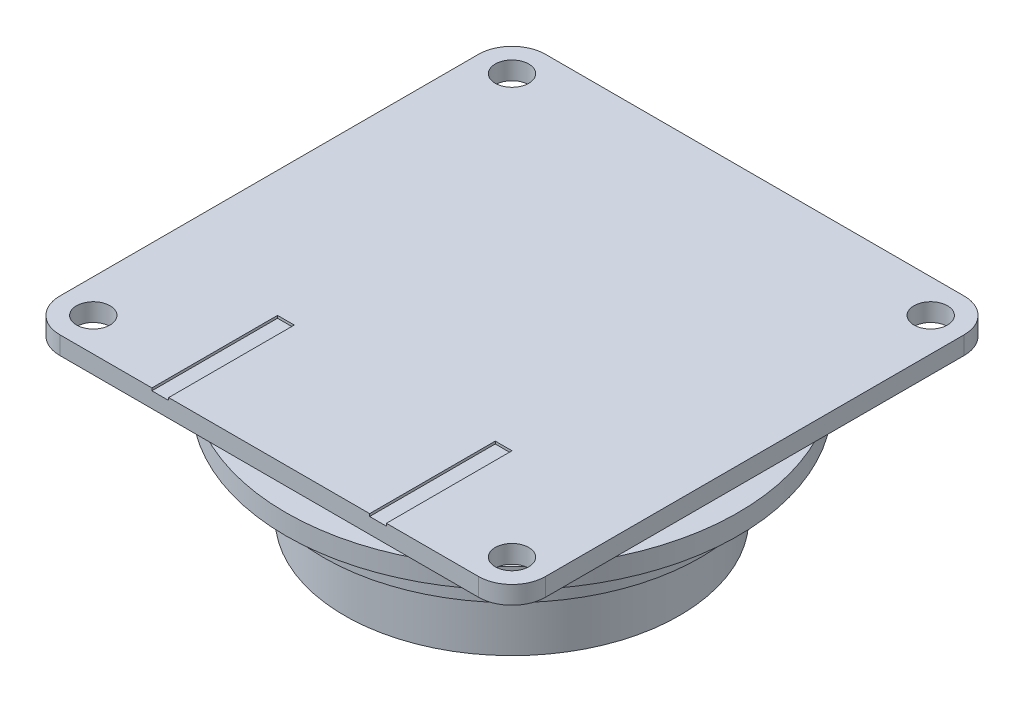
from build123d import *

# Parameters (mm, degrees)
SKETCH1_R            = 20
BOSS_EXTRUDE1_DEPTH  = 7.25
SKETCH2_R            = 22.5
BOSS_EXTRUDE2_DEPTH  = 4.5
SKETCH3_R            = 27
BOSS_EXTRUDE3_DEPTH  = 2.4
CUT_EXTRUDE1_REACH   = 42.721
SKETCH4_R            = 1
SKETCH5_R            = 23.5
BOSS_EXTRUDE4_DEPTH  = 2.5
SKETCH6_R            = 20.5
BOSS_EXTRUDE5_DEPTH  = 1
SKETCH8_R            = 17.25
BOSS_EXTRUDE8_DEPTH  = 1.25
SKETCH10_R           = 2
BOSS_EXTRUDE10_DEPTH = 2.15
SKETCH11_W           = 2
SKETCH11_H           = 15
CUT_EXTRUDE2_DEPTH   = 0.3


with BuildPart() as part:
    # Sketch1 → Boss-Extrude1 (new body)
    with BuildSketch(Plane(origin=(0, 0, 0), x_dir=(1, 0, 0), z_dir=(0, 1, 0))):
        with Locations(Location((0, 0, 0), (0, 0, 90))):
            Circle(SKETCH1_R)
    extrude(amount=BOSS_EXTRUDE1_DEPTH)

    # Sketch2 → Boss-Extrude2 (add)
    with BuildSketch(Plane(origin=(0, 7.25, 0), x_dir=(1, 0, 0), z_dir=(0, 1, 0))):
        with Locations(Location((0, 0, 0), (0, 0, 270))):
            Circle(SKETCH2_R)
    extrude(amount=BOSS_EXTRUDE2_DEPTH)

    # Sketch3 → Boss-Extrude3 (add)
    with BuildSketch(Plane(origin=(0, 11.75, 0), x_dir=(1, 0, 0), z_dir=(0, 1, 0))):
        with Locations(Location((0, 0, 0), (0, 0, 270))):
            Circle(SKETCH3_R)
    extrude(amount=BOSS_EXTRUDE3_DEPTH)

    # Sketch4 → Cut-Extrude1 (cut, up to next)
    with BuildSketch(Plane(origin=(0, 14.15, 0), x_dir=(1, 0, 0), z_dir=(0, 1, 0)), mode=Mode.PRIVATE) as cut_extrude1_sk1:
        with Locations(Location((17.735675135, -15.417387181, 0), (0, 0, 270))):
            Circle(SKETCH4_R)
    cut_extrude1_tool1 = extrude(cut_extrude1_sk1.sketch, amount=-CUT_EXTRUDE1_REACH, mode=Mode.PRIVATE) & part.part
    # Sketch4 → Cut-Extrude1 (cut, up to next)
    with BuildSketch(Plane(origin=(0, 14.15, 0), x_dir=(1, 0, 0), z_dir=(0, 1, 0)), mode=Mode.PRIVATE) as cut_extrude1_sk2:
        with Locations(Location((-4.484011391, -23.068238811, 0), (0, 0, 270))):
            Circle(SKETCH4_R)
    cut_extrude1_tool2 = extrude(cut_extrude1_sk2.sketch, amount=-CUT_EXTRUDE1_REACH, mode=Mode.PRIVATE) & part.part
    # Sketch4 → Cut-Extrude1 (cut, up to next)
    with BuildSketch(Plane(origin=(0, 14.15, 0), x_dir=(1, 0, 0), z_dir=(0, 1, 0)), mode=Mode.PRIVATE) as cut_extrude1_sk3:
        with Locations(Location((-22.219686527, -7.65085163, 0), (0, 0, 270))):
            Circle(SKETCH4_R)
    cut_extrude1_tool3 = extrude(cut_extrude1_sk3.sketch, amount=-CUT_EXTRUDE1_REACH, mode=Mode.PRIVATE) & part.part
    # Sketch4 → Cut-Extrude1 (cut, up to next)
    with BuildSketch(Plane(origin=(0, 14.15, 0), x_dir=(1, 0, 0), z_dir=(0, 1, 0)), mode=Mode.PRIVATE) as cut_extrude1_sk4:
        with Locations(Location((-17.735675135, 15.417387181, 0), (0, 0, 270))):
            Circle(SKETCH4_R)
    cut_extrude1_tool4 = extrude(cut_extrude1_sk4.sketch, amount=-CUT_EXTRUDE1_REACH, mode=Mode.PRIVATE) & part.part
    # Sketch4 → Cut-Extrude1 (cut, up to next)
    with BuildSketch(Plane(origin=(0, 14.15, 0), x_dir=(1, 0, 0), z_dir=(0, 1, 0)), mode=Mode.PRIVATE) as cut_extrude1_sk5:
        with Locations(Location((4.484011391, 23.068238811, 0), (0, 0, 270))):
            Circle(SKETCH4_R)
    cut_extrude1_tool5 = extrude(cut_extrude1_sk5.sketch, amount=-CUT_EXTRUDE1_REACH, mode=Mode.PRIVATE) & part.part
    # Sketch4 → Cut-Extrude1 (cut, up to next)
    with BuildSketch(Plane(origin=(0, 14.15, 0), x_dir=(1, 0, 0), z_dir=(0, 1, 0)), mode=Mode.PRIVATE) as cut_extrude1_sk6:
        with Locations(Location((22.219686527, 7.65085163, 0), (0, 0, 270))):
            Circle(SKETCH4_R)
    cut_extrude1_tool6 = extrude(cut_extrude1_sk6.sketch, amount=-CUT_EXTRUDE1_REACH, mode=Mode.PRIVATE) & part.part
    add(cut_extrude1_tool1.solids().sort_by_distance((17.735675, 14.15, 15.417387))[0], mode=Mode.SUBTRACT)
    add(cut_extrude1_tool2.solids().sort_by_distance((-4.484011, 14.15, 23.068239))[0], mode=Mode.SUBTRACT)
    add(cut_extrude1_tool3.solids().sort_by_distance((-22.219687, 14.15, 7.650852))[0], mode=Mode.SUBTRACT)
    add(cut_extrude1_tool4.solids().sort_by_distance((-17.735675, 14.15, -15.417387))[0], mode=Mode.SUBTRACT)
    add(cut_extrude1_tool5.solids().sort_by_distance((4.484011, 14.15, -23.068239))[0], mode=Mode.SUBTRACT)
    add(cut_extrude1_tool6.solids().sort_by_distance((22.219687, 14.15, -7.650852))[0], mode=Mode.SUBTRACT)

    # Sketch5 → Boss-Extrude4 (add)
    with BuildSketch(Plane(origin=(0, 14.15, 0), x_dir=(1, 0, 0), z_dir=(0, 1, 0))):
        with Locations(Location((0, 0, 0), (0, 0, 81.438302268))):
            Circle(SKETCH5_R)
    extrude(amount=BOSS_EXTRUDE4_DEPTH)

    # Sketch6 → Boss-Extrude5 (add)
    with BuildSketch(Plane(origin=(0, 16.65, 0), x_dir=(1, 0, 0), z_dir=(0, 1, 0))):
        with Locations(Location((0, 0, 0), (0, 0, 270))):
            Circle(SKETCH6_R)
    extrude(amount=BOSS_EXTRUDE5_DEPTH)

    # Cut-Sweep1: sweep along a curve in space
    with BuildLine() as cut_sweep1_path:
        ThreePointArc((0, 17.65, 20.5), (14.495689014, 17.65, 14.495689014), (20.5, 17.65, 0))
        ThreePointArc((20.5, 17.65, 0), (14.495689014, 17.65, -14.495689014), (0, 17.65, -20.5))
        ThreePointArc((0, 17.65, -20.5), (-14.495689014, 17.65, -14.495689014), (-20.5, 17.65, 0))
        ThreePointArc((-20.5, 17.65, 0), (-14.495689014, 17.65, 14.495689014), (0, 17.65, 20.5))
    # Sketch7 → Cut-Sweep1 (sweep, cut)
    with BuildSketch(Plane.XY):
        with BuildLine():
            Line((20.5, 17.65), (20.5, 14.4))
            ThreePointArc((20.5, 14.4), (18.201902961, 15.351902961), (17.25, 17.65))
            Line((17.25, 17.65), (20.5, 17.65))
        make_face()
    sweep(path=cut_sweep1_path.line, mode=Mode.SUBTRACT)

    # Sketch8 → Boss-Extrude8 (add)
    with BuildSketch(Plane(origin=(0, 17.65, 0), x_dir=(1, 0, 0), z_dir=(0, 1, 0))):
        with Locations(Location((0, 0, 0), (0, 0, 270))):
            Circle(SKETCH8_R)
    extrude(amount=BOSS_EXTRUDE8_DEPTH)

    # Sketch10 → Boss-Extrude10 (add)
    with BuildSketch(Plane(origin=(0, 18.9, 0), x_dir=(1, 0, 0), z_dir=(0, 1, 0))):
        with BuildLine():
            Line((-25, -29), (25, -29))
            ThreePointArc((25, -29), (27.828427125, -27.828427125), (29, -25))
            Line((29, -25), (29, 25))
            ThreePointArc((29, 25), (27.828427125, 27.828427125), (25, 29))
            Line((25, 29), (-25, 29))
            ThreePointArc((-25, 29), (-27.828427125, 27.828427125), (-29, 25))
            Line((-29, 25), (-29, -25))
            ThreePointArc((-29, -25), (-27.828427125, -27.828427125), (-25, -29))
        make_face()
        with Locations(Location((-25, 25, 0), (0, 0, 90))):
            Circle(SKETCH10_R, mode=Mode.SUBTRACT)
        with Locations(Location((25, 25, 0), (0, 0, 90))):
            Circle(SKETCH10_R, mode=Mode.SUBTRACT)
        with Locations(Location((25, -25, 0), (0, 0, 90))):
            Circle(SKETCH10_R, mode=Mode.SUBTRACT)
        with Locations(Location((-25, -25, 0), (0, 0, 90))):
            Circle(SKETCH10_R, mode=Mode.SUBTRACT)
    extrude(amount=BOSS_EXTRUDE10_DEPTH)

    # Sketch11 → Cut-Extrude2 (cut)
    with BuildSketch(Plane(origin=(0, 21.05, 0), x_dir=(1, 0, 0), z_dir=(0, 1, 0))):
        with Locations((-13, -21.5)):
            Rectangle(SKETCH11_W, SKETCH11_H)
        with Locations((13, -21.5)):
            Rectangle(SKETCH11_W, SKETCH11_H)
    extrude(amount=-CUT_EXTRUDE2_DEPTH, mode=Mode.SUBTRACT)


solid = part.part
